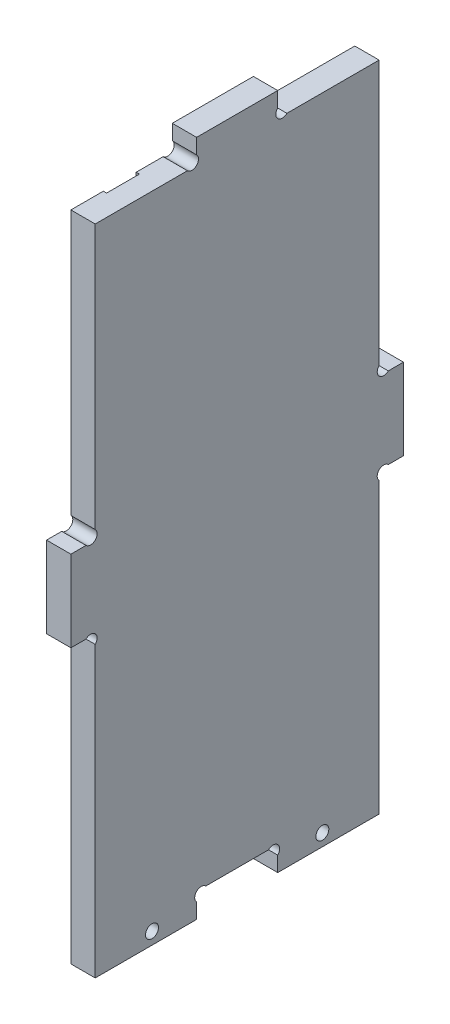
from build123d import *

# Parameters (mm, degrees)
ESQUISSE1_R             = 1.6
BOSS_EXTRU_1_DEPTH      = 6
ENL_V_MAT_EXTRU_1_DEPTH = 0.8


with BuildPart() as part:
    # Esquisse1 → Boss.-Extru.1 (new body)
    with BuildSketch(Plane(origin=(0, 0, 0), x_dir=(0, 0, -1), z_dir=(1, 0, 0))):
        with BuildLine():
            Line((3.7372583, 73.5), (0, 73.5))
            Line((0, 73.5), (0, 93.5))
            Line((0, 93.5), (3.7372583, 93.5))
            ThreePointArc((3.7372583, 93.5), (6, 93.5), (6, 95.7627417))
            Line((6, 95.7627417), (6, 161))
            Line((6, 161), (28.7372583, 161))
            ThreePointArc((28.7372583, 161), (31, 161), (31, 163.2627417))
            Line((31, 163.2627417), (31, 167))
            Line((31, 167), (51, 167))
            Line((51, 167), (51, 163.2627417))
            ThreePointArc((51, 163.2627417), (51, 161), (53.2627417, 161))
            Line((53.2627417, 161), (76, 161))
            Line((76, 161), (76, 95.7627417))
            ThreePointArc((76, 95.7627417), (76, 93.5), (78.2627417, 93.5))
            Line((78.2627417, 93.5), (82, 93.5))
            Line((82, 93.5), (82, 73.5))
            Line((82, 73.5), (78.2627417, 73.5))
            ThreePointArc((78.2627417, 73.5), (76, 73.5), (76, 71.2372583))
            Line((76, 71.2372583), (76, 0))
            Line((76, 0), (51, 0))
            Line((51, 0), (51, 3.7372583))
            ThreePointArc((51, 3.7372583), (51, 6), (48.7372583, 6))
            Line((48.7372583, 6), (33.2627417, 6))
            ThreePointArc((33.2627417, 6), (31, 6), (31, 3.7372583))
            Line((31, 3.7372583), (31, 0))
            Line((31, 0), (6, 0))
            Line((6, 0), (6, 71.2372583))
            ThreePointArc((6, 71.2372583), (6, 73.5), (3.7372583, 73.5))
        make_face()
        with Locations((20, 3)):
            Circle(ESQUISSE1_R, mode=Mode.SUBTRACT)
        with Locations(Location((62, 3, 0), (0, 0, 180))):  # turned: the seam where the file's is
            Circle(ESQUISSE1_R, mode=Mode.SUBTRACT)
    extrude(amount=BOSS_EXTRU_1_DEPTH)

    # Esquisse2 → Enlèv. mat.-Extru.1 (cut)
    with BuildSketch(Plane.ZY):
        with BuildLine():
            Line((-22.1, 165.86112534), (-14, 165.86112534))
            Line((-14, 165.86112534), (-14, 8.2627417))
            ThreePointArc((-14, 8.2627417), (-14, 6), (-16.2627417, 6))
            Line((-16.2627417, 6), (-19.8372583, 6))
            ThreePointArc((-19.8372583, 6), (-22.1, 6), (-22.1, 8.2627417))
            Line((-22.1, 8.2627417), (-22.1, 165.86112534))
        make_face()
    extrude(amount=-ENL_V_MAT_EXTRU_1_DEPTH, mode=Mode.SUBTRACT)


solid = part.part
